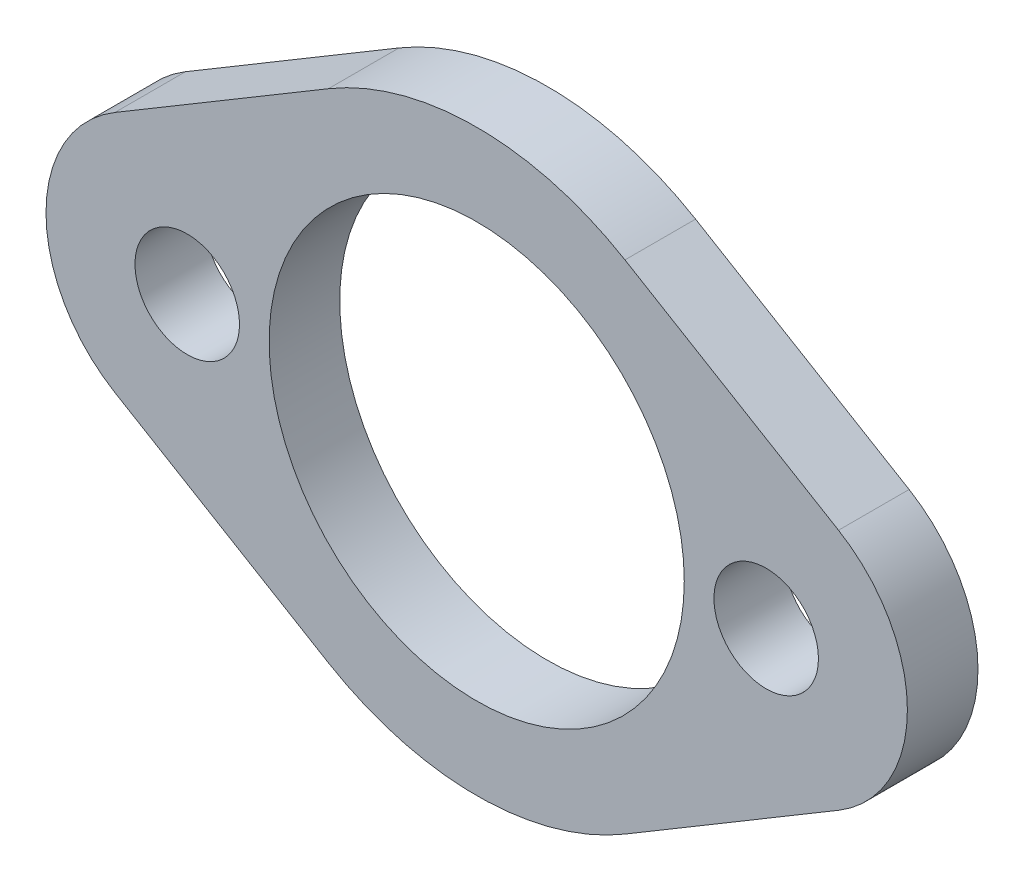
from build123d import *

# Parameters (mm, degrees)
SKETCH1_R           = 18.669
SKETCH1_R_2         = 4.699
BOSS_EXTRUDE1_DEPTH = 6.35


with BuildPart() as part:
    # Sketch1 → Boss-Extrude1 (new body)
    with BuildSketch(Plane.XY):
        with BuildLine():
            Line((13.335, 22.360657414), (32.539878049, 10.907637763))
            ThreePointArc((32.539878049, 10.907637763), (38.735, 0), (32.539878049, -10.907637763))
            Line((32.539878049, -10.907637763), (13.335, -22.360657414))
            ThreePointArc((13.335, -22.360657414), (0, -26.035), (-13.335, -22.360657414))
            Line((-13.335, -22.360657414), (-32.539878049, -10.907637763))
            ThreePointArc((-32.539878049, -10.907637763), (-38.735, 0), (-32.539878049, 10.907637763))
            Line((-32.539878049, 10.907637763), (-13.335, 22.360657414))
            ThreePointArc((-13.335, 22.360657414), (0, 26.035), (13.335, 22.360657414))
        make_face()
        Circle(SKETCH1_R, mode=Mode.SUBTRACT)
        with Locations((26.035, 0)):
            Circle(SKETCH1_R_2, mode=Mode.SUBTRACT)
        with Locations((-26.035, 0)):
            Circle(SKETCH1_R_2, mode=Mode.SUBTRACT)
    extrude(amount=BOSS_EXTRUDE1_DEPTH)


solid = part.part
